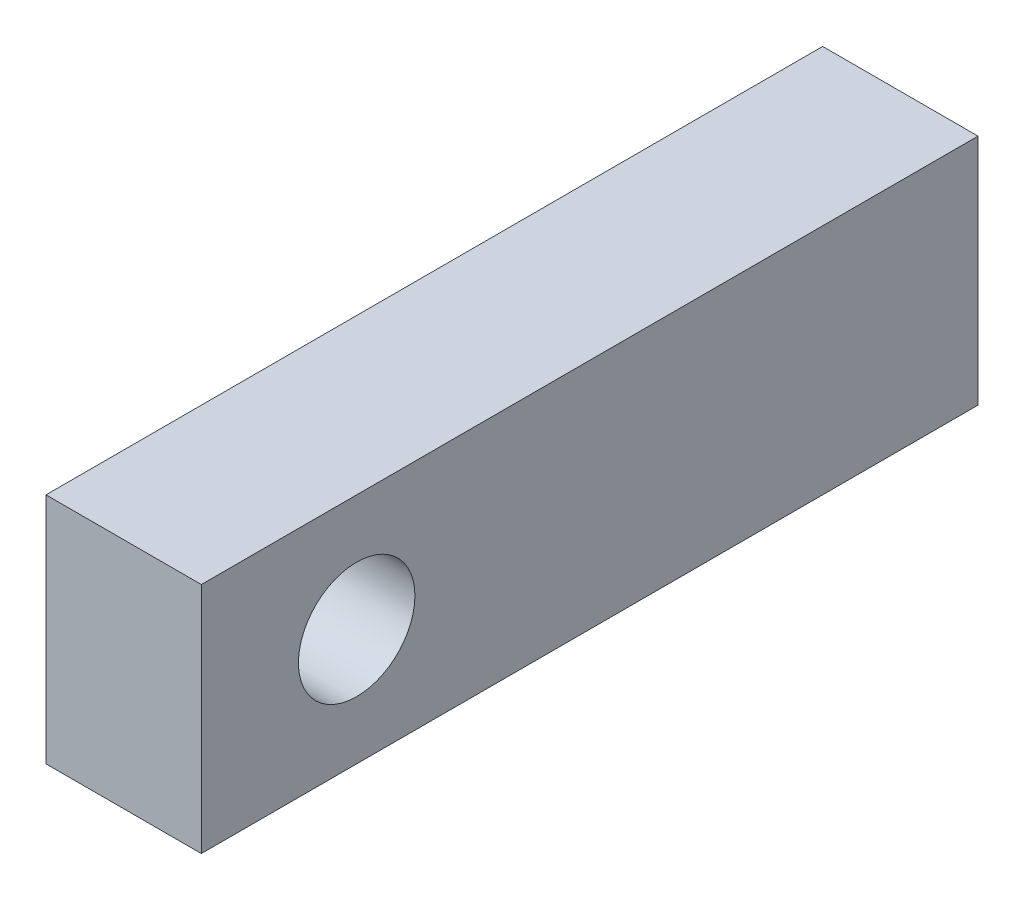
from build123d import *

# Parameters (mm, degrees)
SKETCH1_W           = 25.4
SKETCH1_H           = 38.1
BOSS_EXTRUDE1_DEPTH = 127
SKETCH2_R           = 9.525
CUT_EXTRUDE1_DEPTH  = 26.4


with BuildPart() as part:
    # Sketch1 → Boss-Extrude1 (new body)
    with BuildSketch(Plane.XY):
        with Locations((12.7, 19.05)):
            Rectangle(SKETCH1_W, SKETCH1_H)
    extrude(amount=BOSS_EXTRUDE1_DEPTH)

    # Sketch2 → Cut-Extrude1 (cut, through all)
    with BuildSketch(Plane(origin=(25.4, 0, 0), x_dir=(0, 0, -1), z_dir=(1, 0, 0))):
        with Locations((-101.6, 19.05)):
            Circle(SKETCH2_R)
    extrude(amount=-CUT_EXTRUDE1_DEPTH, mode=Mode.SUBTRACT)


solid = part.part
